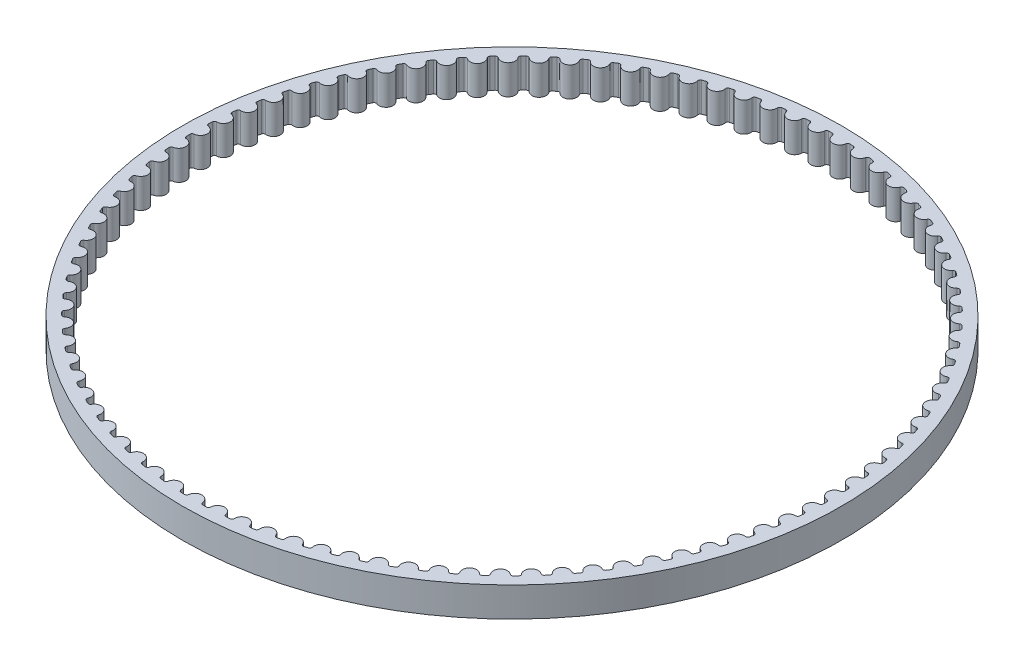
from build123d import *

# Parameters (mm, degrees)
SKETCH1_R           = 44.568299464
BOSS_EXTRUDE1_DEPTH = 4


with BuildPart() as part:
    # Sketch1 → Boss-Extrude1 (new body)
    with BuildSketch(Plane(origin=(0, 0, 0), x_dir=(1, 0, 0), z_dir=(0, 1, 0))):
        Circle(SKETCH1_R)
        with BuildLine():
            ThreePointArc((-1.725274037, -43.033729193), (-1.486551409, -43.042636811), (-1.247783047, -43.050220164))
            ThreePointArc((-1.247783047, -43.050220164), (-1.041950756, -42.976123674), (-0.941665266, -42.781701344))
            ThreePointArc((-0.941665266, -42.781701344), (0, -41.931243432), (0.941665266, -42.781701344))
            ThreePointArc((0.941665266, -42.781701344), (1.041950756, -42.976123674), (1.247783047, -43.050220164))
            ThreePointArc((1.247783047, -43.050220164), (1.486551409, -43.042636811), (1.725274037, -43.033729193))
            ThreePointArc((1.725274037, -43.033729193), (1.925503883, -42.945608649), (2.012137001, -42.744730764))
            ThreePointArc((2.012137001, -42.744730764), (2.892884471, -41.831332697), (3.89098007, -42.614797635))
            ThreePointArc((3.89098007, -42.614797635), (4.004440026, -42.801837898), (4.214893875, -42.861557232))
            ThreePointArc((4.214893875, -42.861557232), (4.452570134, -42.837519045), (4.690109403, -42.812162904))
            ThreePointArc((4.690109403, -42.812162904), (4.883782619, -42.710438241), (4.956350519, -42.504062075))
            ThreePointArc((4.956350519, -42.504062075), (5.771983029, -41.532076611), (6.821752581, -42.244815008))
            ThreePointArc((6.821752581, -42.244815008), (6.947846315, -42.423581874), (7.161918815, -42.46863946))
            ThreePointArc((7.161918815, -42.46863946), (7.397370334, -42.428260993), (7.632594263, -42.386577162))
            ThreePointArc((7.632594263, -42.386577162), (7.818787908, -42.271733145), (7.87694477, -42.060842175))
            ThreePointArc((7.87694477, -42.060842175), (8.62357546, -41.034901267), (9.720016335, -41.6735166))
            ThreePointArc((9.720016335, -41.6735166), (9.858142952, -41.843158162), (10.074813951, -41.873339282))
            ThreePointArc((10.074813951, -41.873339282), (10.306918696, -41.816812955), (10.538706335, -41.759000078))
            ThreePointArc((10.538706335, -41.759000078), (10.716533111, -41.63158399), (10.760001792, -41.417183207))
            ThreePointArc((10.760001792, -41.417183207), (11.434072627, -40.342175932), (12.571959784, -40.903624907))
            ThreePointArc((12.571959784, -40.903624907), (12.721461049, -41.063332746), (12.93969801, -41.078493572))
            ThreePointArc((12.93969801, -41.078493572), (13.167349896, -41.00608876), (13.394596672, -40.932422341))
            ThreePointArc((13.394596672, -40.932422341), (13.563209153, -40.793041378), (13.591782505, -40.5761525))
            ThreePointArc((13.591782505, -40.5761525), (14.190081231, -39.457201756), (15.36399212, -39.938808814))
            ThreePointArc((15.36399212, -39.938808814), (15.52415559, -40.087821849), (15.742918515, -40.087890134))
            ThreePointArc((15.742918515, -40.087890134), (15.965032678, -39.999951879), (16.186655656, -39.910782972))
            ThreePointArc((16.186655656, -39.910782972), (16.345250327, -39.760101347), (16.358792185, -39.541757948))
            ThreePointArc((16.358792185, -39.541757948), (16.878467636, -38.384196045), (18.082808037, -38.783666109))
            ThreePointArc((18.082808037, -38.783666109), (18.252870461, -38.921274226), (18.471116844, -38.906249643))
            ThreePointArc((18.471116844, -38.906249643), (18.686634809, -38.803197011), (18.901577855, -38.698950546))
            ThreePointArc((18.901577855, -38.698950546), (19.04939894, -38.537686327), (19.04784477, -38.318928912))
            ThreePointArc((19.04784477, -38.318928912), (19.486420455, -37.12827216), (20.715451138, -37.443701573))
            ThreePointArc((20.715451138, -37.443701573), (20.894602091, -37.569249006), (21.111291889, -37.539203155))
            ThreePointArc((21.111291889, -37.539203155), (21.319186615, -37.421527238), (21.526425427, -37.302699997))
            ThreePointArc((21.526425427, -37.302699997), (21.662768492, -37.131621681), (21.646125701, -36.91349273))
            ThreePointArc((21.646125701, -36.91349273), (22.001511608, -35.69541515), (23.249375681, -35.925300748))
            ThreePointArc((23.249375681, -35.925300748), (23.436761427, -36.038189205), (23.650862015, -35.993265268))
            ThreePointArc((23.650862015, -35.993265268), (23.850142788, -35.861526846), (24.048689779, -35.728685095))
            ThreePointArc((24.048689779, -35.728685095), (24.172905087, -35.548607948), (24.141252985, -35.332146944))
            ThreePointArc((24.141252985, -35.332146944), (24.411755538, -34.092453231), (25.672506361, -34.235699504))
            ThreePointArc((25.672506361, -34.235699504), (25.867233922, -34.335391022), (26.077725013, -34.275803082))
            ThreePointArc((26.077725013, -34.275803082), (26.267442169, -34.130629948), (26.456351172, -33.984406739))
            ThreePointArc((26.456351172, -33.984406739), (26.567846781, -33.79618891), (26.521336205, -33.582427388))
            ThreePointArc((26.521336205, -33.582427388), (26.705666336, -32.327025247), (27.973295858, -32.38294956))
            ThreePointArc((27.973295858, -32.38294956), (28.174437268, -32.468969063), (28.380315775, -32.395001084))
            ThreePointArc((28.380315775, -32.395001084), (28.559565227, -32.237085054), (28.737936004, -32.078177207))
            ThreePointArc((28.737936004, -32.078177207), (28.836180586, -31.882715641), (28.77503318, -31.672672273))
            ThreePointArc((28.77503318, -31.672672273), (28.872312472, -30.407544266), (30.14077986, -30.375880116))
            ThreePointArc((30.14077986, -30.375880116), (30.347376589, -30.447817681), (30.547661408, -30.359822154))
            ThreePointArc((30.547661408, -30.359822154), (30.71558895, -30.18991577), (30.882571484, -30.019080553))
            ThreePointArc((30.882571484, -30.019080553), (30.967096858, -29.817306712), (30.891604018, -29.61198245))
            ThreePointArc((30.891604018, -29.61198245), (30.90136889, -28.343157489), (32.164629321, -28.224055769))
            ThreePointArc((32.164629321, -28.224055769), (32.375696841, -28.281568582), (32.569433524, -28.179964845))
            ThreePointArc((32.569433524, -28.179964845), (32.725238903, -27.998877789), (32.880037447, -27.816929309))
            ThreePointArc((32.880037447, -27.816929309), (32.950440812, -27.609804738), (32.860962294, -27.410178045))
            ThreePointArc((32.860962294, -27.410178045), (32.783166214, -26.143702659), (34.035199675, -25.937730943))
            ThreePointArc((34.035199675, -25.937730943), (34.249732153, -25.98054493), (34.435997456, -25.865817171))
            ThreePointArc((34.435997456, -25.865817171), (34.578938191, -25.674412404), (34.720815058, -25.48221773))
            ThreePointArc((34.720815058, -25.48221773), (34.77676091, -25.270729472), (34.673723121, -25.07775166))
            ThreePointArc((34.673723121, -25.07775166), (34.508736821, -23.81966118), (35.743576803, -23.527801018))
            ThreePointArc((35.743576803, -23.527801018), (35.960551895, -23.555712149), (36.138458179, -23.428407099))
            ThreePointArc((36.138458179, -23.428407099), (36.267853091, -23.227596753), (36.396132173, -23.026071778))
            ThreePointArc((36.396132173, -23.026071778), (36.437353904, -22.811227671), (36.321247866, -22.625818368))
            ThreePointArc((36.321247866, -22.625818368), (36.069857582, -21.382108169), (37.28161951, -21.005750406))
            ThreePointArc((37.28161951, -21.005750406), (37.50000323, -21.018625672), (37.668702691, -20.879349998))
            ThreePointArc((37.668702691, -20.879349998), (37.783935154, -20.670091025), (37.898005144, -20.460196109))
            ThreePointArc((37.898005144, -20.460196109), (37.924306314, -20.243019982), (37.795685325, -20.066062747))
            ThreePointArc((37.795685325, -20.066062747), (37.459089046, -18.842659674), (38.641998322, -18.383597827))
            ThreePointArc((38.641998322, -18.383597827), (38.860749972, -18.381375873), (39.01943868, -18.230793285))
            ThreePointArc((39.01943868, -18.230793285), (39.11995956, -18.0140829), (39.219276862, -17.796818287))
            ThreePointArc((39.219276862, -17.796818287), (39.230532134, -17.578345084), (39.090009132, -17.410683199))
            ThreePointArc((39.090009132, -17.410683199), (38.669810891, -16.213417325), (39.818230414, -15.673839033))
            ThreePointArc((39.818230414, -15.673839033), (40.036307544, -15.656530446), (40.184229275, -15.49535854))
            ThreePointArc((40.184229275, -15.49535854), (40.269559544, -15.272229467), (40.353650865, -15.048630522))
            ThreePointArc((40.353650865, -15.048630522), (40.349806602, -14.829901367), (40.198051243, -14.672333817))
            ThreePointArc((40.198051243, -14.672333817), (39.696253478, -13.506910659), (40.804710506, -12.889387258))
            ThreePointArc((40.804710506, -12.889387258), (41.021073878, -12.857074522), (41.157523718, -12.686081356))
            ThreePointArc((41.157523718, -12.686081356), (41.227256737, -12.457596905), (41.295721345, -12.228729179))
            ThreePointArc((41.295721345, -12.228729179), (41.276795867, -12.010786416), (41.114531334, -11.864064083))
            ThreePointArc((41.114531334, -11.864064083), (40.533525339, -10.736037413), (41.59673757, -10.043511683))
            ThreePointArc((41.59673757, -10.043511683), (41.810356114, -9.996348783), (41.934683817, -9.816349216))
            ThreePointArc((41.934683817, -9.816349216), (41.988487278, -9.583598221), (42.040998906, -9.350552373))
            ThreePointArc((42.040998906, -9.350552373), (42.007082402, -9.134434598), (41.83508196, -8.999256681))
            ThreePointArc((41.83508196, -8.999256681), (41.177636493, -7.91400206), (42.190537236, -7.149774202))
            ThreePointArc((42.190537236, -7.149774202), (42.400392963, -7.08798589), (42.51200605, -6.899837702))
            ThreePointArc((42.51200605, -6.899837702), (42.549623555, -6.663929327), (42.585931963, -6.427815926))
            ThreePointArc((42.585931963, -6.427815926), (42.53718606, -6.21455304), (42.356269368, -6.091563722))
            ThreePointArc((42.356269368, -6.091563722), (41.625517457, -5.054252882), (42.583279778, -4.22196479))
            ThreePointArc((42.583279778, -4.22196479), (42.78837263, -4.145845516), (42.886739215, -3.95044532))
            ThreePointArc((42.886739215, -3.95044532), (42.907991499, -3.712503775), (42.92792366, -3.47444801))
            ThreePointArc((42.92792366, -3.47444801), (42.864580655, -3.265056306), (42.675609864, -3.154841688))
            ThreePointArc((42.675609864, -3.154841688), (41.875033874, -2.170417888), (42.773093601, -1.274035793))
            ThreePointArc((42.773093601, -1.274035793), (42.972446216, -1.1839483), (43.057097537, -0.982227266))
            ThreePointArc((43.057097537, -0.982227266), (43.061883323, -0.743386451), (43.065344252, -0.504522766))
            ThreePointArc((43.065344252, -0.504522766), (42.987706002, -0.300000092), (42.791581645, -0.203085396))
            ThreePointArc((42.791581645, -0.203085396), (41.924996685, 0.723760136), (42.759074153, 1.679964565))
            ThreePointArc((42.759074153, 1.679964565), (42.951736527, 1.783590969), (43.022269181, 1.990671548))
            ThreePointArc((43.022269181, 1.990671548), (43.010565663, 2.229273447), (42.997538866, 2.467806759))
            ThreePointArc((42.997538866, 2.467806759), (42.905975354, 2.666485759), (42.703632052, 2.749638689))
            ThreePointArc((42.703632052, 2.749638689), (41.775167794, 3.614489113), (42.541288245, 4.625959126))
            ThreePointArc((42.541288245, 4.625959126), (42.726342252, 4.742630614), (42.782420121, 4.954083906))
            ThreePointArc((42.782420121, 4.954083906), (42.75428307, 5.191309842), (42.724830627, 5.42837606))
            ThreePointArc((42.724830627, 5.42837606), (42.619778194, 5.620264591), (42.412180205, 5.689259495))
            ThreePointArc((42.412180205, 5.689259495), (41.426261204, 6.487993403), (42.120773725, 7.549908886))
            ThreePointArc((42.120773725, 7.549908886), (42.2973375, 7.679069465), (42.338693345, 7.893887797))
            ThreePointArc((42.338693345, 7.893887797), (42.294256849, 8.128607281), (42.248519113, 8.363076677))
            ThreePointArc((42.248519113, 8.363076677), (42.130478382, 8.547260302), (41.918615006, 8.601768387))
            ThreePointArc((41.918615006, 8.601768387), (40.879939614, 9.33057945), (41.499534537, 10.437879891))
            ThreePointArc((41.499534537, 10.437879891), (41.666766671, 10.578914053), (41.693203415, 10.796073719))
            ThreePointArc((41.693203415, 10.796073719), (41.632679233, 11.027168205), (41.570874165, 11.257923426))
            ThreePointArc((41.570874165, 11.257923426), (41.440407655, 11.433524426), (41.225288516, 11.473285937))
            ThreePointArc((41.225288516, 11.473285937), (40.138806496, 12.128701037), (40.680531167, 13.276109646))
            ThreePointArc((40.680531167, 13.276109646), (40.837634725, 13.428345298), (40.849026383, 13.646811432))
            ThreePointArc((40.849026383, 13.646811432), (40.772702941, 13.873179651), (40.695125071, 14.099121043))
            ThreePointArc((40.695125071, 14.099121043), (40.552854513, 14.2653026), (40.335504752, 14.290128054))
            ThreePointArc((40.335504752, 14.290128054), (39.206393685, 14.869023841), (39.667666541, 16.051072692))
            ThreePointArc((39.667666541, 16.051072692), (39.813892852, 16.213784362), (39.810185139, 16.432515874))
            ThreePointArc((39.810185139, 16.432515874), (39.718426152, 16.653079078), (39.625445174, 16.873129927))
            ThreePointArc((39.625445174, 16.873129927), (39.472048551, 17.02910011), (39.253503939, 17.038871203))
            ThreePointArc((39.253503939, 17.038871203), (38.087144554, 17.538488974), (38.465767419, 18.749545067))
            ThreePointArc((38.465767419, 18.749545067), (38.600419649, 18.92195736), (38.581630232, 19.139911895))
            ThreePointArc((38.581630232, 19.139911895), (38.474872974, 19.353618999), (38.366931984, 19.566730663))
            ThreePointArc((38.366931984, 19.566730663), (38.203140303, 19.711746203), (37.984442305, 19.706416371))
            ThreePointArc((37.984442305, 19.706416371), (36.786392834, 20.12437522), (37.080561399, 21.358667321))
            ThreePointArc((37.080561399, 21.358667321), (37.202997867, 21.539958614), (37.169216288, 21.75609752))
            ThreePointArc((37.169216288, 21.75609752), (37.047969505, 21.961930112), (36.925582892, 22.167087016))
            ThreePointArc((36.925582892, 22.167087016), (36.752176694, 22.300456849), (36.534367504, 22.280051491))
            ThreePointArc((36.534367504, 22.280051491), (35.3103372, 22.614359654), (35.518649617, 23.866005799))
            ThreePointArc((35.518649617, 23.866005799), (35.628286858, 24.055312156), (35.579674101, 24.268605432))
            ThreePointArc((35.579674101, 24.268605432), (35.44451559, 24.465582627), (35.308266582, 24.661807106))
            ThreePointArc((35.308266582, 24.661807106), (35.126072226, 24.782895662), (34.910189805, 24.747512019))
            ThreePointArc((34.910189805, 24.747512019), (33.666011729, 24.996576366), (33.787475294, 26.25961189))
            ThreePointArc((33.787475294, 26.25961189), (33.883790838, 26.456031181), (33.820578564, 26.665462387))
            ThreePointArc((33.820578564, 26.665462387), (33.672152417, 26.852645499), (33.522690302, 27.039002453))
            ThreePointArc((33.522690302, 27.039002453), (33.332576027, 27.147232691), (33.119649154, 27.097039383))
            ThreePointArc((33.119649154, 27.097039383), (31.861252381, 27.259673008), (31.895288265, 28.528078973))
            ThreePointArc((31.895288265, 28.528078973), (31.977823123, 28.730675169), (31.900312568, 28.935246271))
            ThreePointArc((31.900312568, 28.935246271), (31.739326104, 29.111743287), (31.577363136, 29.287344641))
            ThreePointArc((31.577363136, 29.287344641), (31.380234924, 29.382200794), (31.171278291, 29.317437014))
            ThreePointArc((31.171278291, 29.317437014), (29.904659655, 29.392864894), (29.851105662, 30.660596767))
            ThreePointArc((29.851105662, 30.660596767), (29.919466519, 30.868404407), (29.828027056, 31.067140529))
            ThreePointArc((29.828027056, 31.067140529), (29.655247447, 31.23211036), (29.481555455, 31.396119293))
            ThreePointArc((29.481555455, 31.396119293), (29.278352711, 31.477149329), (29.074362092, 31.398123707))
            ThreePointArc((29.074362092, 31.398123707), (27.805557608, 31.385986393), (27.664668947, 32.647002856))
            ThreePointArc((27.664668947, 32.647002856), (27.718530031, 32.85903164), (27.613597411, 33.050985715))
            ThreePointArc((27.613597411, 33.050985715), (27.429848032, 33.203642205), (27.245254736, 33.35527714))
            ThreePointArc((27.245254736, 33.35527714), (27.036945815, 33.422094914), (26.838893318, 33.329184041))
            ThreePointArc((26.838893318, 33.329184041), (25.573949416, 33.229539374), (25.346397485, 34.477831108))
            ThreePointArc((25.346397485, 34.477831108), (25.385502125, 34.693070623), (25.2675764, 34.877327902))
            ThreePointArc((25.2675764, 34.877327902), (25.073732899, 35.016943573), (24.879117971, 35.155481901))
            ThreePointArc((24.879117971, 35.155481901), (24.666695558, 35.207768995), (24.475524994, 35.101415636))
            ThreePointArc((24.475524994, 35.101415636), (23.220469709, 34.914738467), (22.907338897, 36.144356794))
            ThreePointArc((22.907338897, 36.144356794), (22.931500741, 36.361781325), (22.80114388, 36.537463739))
            ThreePointArc((22.80114388, 36.537463739), (22.598130011, 36.663373259), (22.394420879, 36.788154781))
            ThreePointArc((22.394420879, 36.788154781), (22.178897265, 36.825662024), (21.995519648, 36.706373))
            ThreePointArc((21.995519648, 36.706373), (20.756333889, 36.433552932), (20.359116407, 37.638638159))
            ThreePointArc((20.359116407, 37.638638159), (20.368220313, 37.857211581), (20.226053526, 38.023481922))
            ThreePointArc((20.226053526, 38.023481922), (20.014836741, 38.135085275), (19.803004174, 38.245515351))
            ThreePointArc((19.803004174, 38.245515351), (19.585406426, 38.268064003), (19.410695634, 38.13640778))
            ThreePointArc((19.410695634, 38.13640778), (18.193284686, 37.778744925), (17.713873456, 38.953554274))
            ThreePointArc((17.713873456, 38.953554274), (17.707876039, 39.172234983), (17.554576816, 39.328300898))
            ThreePointArc((17.554576816, 39.328300898), (17.336163661, 39.425066243), (17.117217135, 39.520618622))
            ThreePointArc((17.117217135, 39.520618622), (16.898582205, 39.52810123), (16.733370815, 39.384705211))
            ThreePointArc((16.733370815, 39.384705211), (15.543536196, 38.943903994), (14.984215831, 40.082838963))
            ThreePointArc((14.984215831, 40.082838963), (14.963145672, 40.300584847), (14.799444553, 40.44570261))
            ThreePointArc((14.799444553, 40.44570261), (14.574875865, 40.527168816), (14.349858761, 40.607388149))
            ThreePointArc((14.349858761, 40.607388149), (14.131228546, 40.599769053), (13.976303865, 40.445316585))
            ThreePointArc((13.976303865, 40.445316585), (12.819715678, 39.923477625), (12.183151594, 41.02111067))
            ThreePointArc((12.183151594, 41.02111067), (12.147109102, 41.236884071), (11.973786197, 41.370362131))
            ThreePointArc((11.973786197, 41.370362131), (11.744132148, 41.436140974), (11.514116775, 41.500644978))
            ThreePointArc((11.514116775, 41.500644978), (11.296533146, 41.477960488), (11.152633461, 41.313187607))
            ThreePointArc((11.152633461, 41.313187607), (10.034803376, 40.712797705), (9.324029092, 41.763898104))
            ThreePointArc((9.324029092, 41.763898104), (9.273186025, 41.976670763), (9.091067297, 42.097873036))
            ThreePointArc((9.091067297, 42.097873036), (8.857422294, 42.14765105), (8.62350478, 42.196132335))
            ThreePointArc((8.62350478, 42.196132335), (8.408004622, 42.158490553), (8.275815681, 41.984182476))
            ThreePointArc((8.275815681, 41.984182476), (7.202070667, 41.308102763), (6.420473344, 42.307661545))
            ThreePointArc((6.420473344, 42.307661545), (6.355071993, 42.516419503), (6.165025322, 42.624768404))
            ThreePointArc((6.165025322, 42.624768404), (5.928502789, 42.658308375), (5.691797857, 42.690535905))
            ThreePointArc((5.691797857, 42.690535905), (5.479408127, 42.63811621), (5.35955987, 42.455103596))
            ThreePointArc((5.35955987, 42.455103596), (4.335016811, 41.706555899), (3.486321118, 42.649809712))
            ThreePointArc((3.486321118, 42.649809712), (3.40667315, 42.853558142), (3.209604193, 42.94853734))
            ThreePointArc((3.209604193, 42.94853734), (2.971331268, 42.965679434), (2.732966925, 42.981499631))
            ThreePointArc((2.732966925, 42.981499631), (2.524699757, 42.914551827), (2.417763315, 42.723706814))
            ThreePointArc((2.417763315, 42.723706814), (1.447304625, 41.906258304), (0.535554983, 42.788712112))
            ThreePointArc((0.535554983, 42.788712112), (0.442039957, 42.986480061), (0.238887839, 43.067636937))
            ThreePointArc((0.238887839, 43.067636937), (0, 43.068299464), (-0.238887839, 43.067636937))
            ThreePointArc((-0.238887839, 43.067636937), (-0.442039957, 42.986480061), (-0.535554983, 42.788712112))
            ThreePointArc((-0.535554983, 42.788712112), (-1.447304625, 41.906258304), (-2.417763315, 42.723706814))
            ThreePointArc((-2.417763315, 42.723706814), (-2.524699757, 42.914551827), (-2.732966925, 42.981499631))
            ThreePointArc((-2.732966925, 42.981499631), (-2.971331268, 42.965679434), (-3.209604193, 42.94853734))
            ThreePointArc((-3.209604193, 42.94853734), (-3.40667315, 42.853558142), (-3.486321118, 42.649809712))
            ThreePointArc((-3.486321118, 42.649809712), (-4.335016811, 41.706555899), (-5.35955987, 42.455103596))
            ThreePointArc((-5.35955987, 42.455103596), (-5.479408127, 42.63811621), (-5.691797857, 42.690535905))
            ThreePointArc((-5.691797857, 42.690535905), (-5.928502789, 42.658308375), (-6.165025322, 42.624768404))
            ThreePointArc((-6.165025322, 42.624768404), (-6.355071993, 42.516419503), (-6.420473344, 42.307661545))
            ThreePointArc((-6.420473344, 42.307661545), (-7.202070667, 41.308102763), (-8.275815681, 41.984182476))
            ThreePointArc((-8.275815681, 41.984182476), (-8.408004622, 42.158490553), (-8.62350478, 42.196132335))
            ThreePointArc((-8.62350478, 42.196132335), (-8.857422294, 42.14765105), (-9.091067297, 42.097873036))
            ThreePointArc((-9.091067297, 42.097873036), (-9.273186025, 41.976670763), (-9.324029092, 41.763898104))
            ThreePointArc((-9.324029092, 41.763898104), (-10.034803376, 40.712797705), (-11.152633461, 41.313187607))
            ThreePointArc((-11.152633461, 41.313187607), (-11.296533146, 41.477960488), (-11.514116775, 41.500644978))
            ThreePointArc((-11.514116775, 41.500644978), (-11.744132148, 41.436140974), (-11.973786197, 41.370362131))
            ThreePointArc((-11.973786197, 41.370362131), (-12.147109102, 41.236884071), (-12.183151594, 41.02111067))
            ThreePointArc((-12.183151594, 41.02111067), (-12.819715678, 39.923477625), (-13.976303865, 40.445316585))
            ThreePointArc((-13.976303865, 40.445316585), (-14.131228546, 40.599769053), (-14.349858761, 40.607388149))
            ThreePointArc((-14.349858761, 40.607388149), (-14.574875865, 40.527168816), (-14.799444553, 40.44570261))
            ThreePointArc((-14.799444553, 40.44570261), (-14.963145672, 40.300584847), (-14.984215831, 40.082838963))
            ThreePointArc((-14.984215831, 40.082838963), (-15.543536196, 38.943903994), (-16.733370815, 39.384705211))
            ThreePointArc((-16.733370815, 39.384705211), (-16.898582205, 39.52810123), (-17.117217135, 39.520618622))
            ThreePointArc((-17.117217135, 39.520618622), (-17.336163661, 39.425066243), (-17.554576816, 39.328300898))
            ThreePointArc((-17.554576816, 39.328300898), (-17.707876039, 39.172234983), (-17.713873456, 38.953554274))
            ThreePointArc((-17.713873456, 38.953554274), (-18.193284686, 37.778744925), (-19.410695634, 38.13640778))
            ThreePointArc((-19.410695634, 38.13640778), (-19.585406426, 38.268064003), (-19.803004174, 38.245515351))
            ThreePointArc((-19.803004174, 38.245515351), (-20.014836741, 38.135085275), (-20.226053526, 38.023481922))
            ThreePointArc((-20.226053526, 38.023481922), (-20.368220313, 37.857211581), (-20.359116407, 37.638638159))
            ThreePointArc((-20.359116407, 37.638638159), (-20.756333889, 36.433552932), (-21.995519648, 36.706373))
            ThreePointArc((-21.995519648, 36.706373), (-22.178897265, 36.825662024), (-22.394420879, 36.788154781))
            ThreePointArc((-22.394420879, 36.788154781), (-22.598130011, 36.663373259), (-22.80114388, 36.537463739))
            ThreePointArc((-22.80114388, 36.537463739), (-22.931500741, 36.361781325), (-22.907338897, 36.144356794))
            ThreePointArc((-22.907338897, 36.144356794), (-23.220469709, 34.914738467), (-24.475524994, 35.101415636))
            ThreePointArc((-24.475524994, 35.101415636), (-24.666695558, 35.207768995), (-24.879117971, 35.155481901))
            ThreePointArc((-24.879117971, 35.155481901), (-25.073732899, 35.016943573), (-25.2675764, 34.877327902))
            ThreePointArc((-25.2675764, 34.877327902), (-25.385502125, 34.693070623), (-25.346397485, 34.477831108))
            ThreePointArc((-25.346397485, 34.477831108), (-25.573949416, 33.229539374), (-26.838893318, 33.329184041))
            ThreePointArc((-26.838893318, 33.329184041), (-27.036945815, 33.422094914), (-27.245254736, 33.35527714))
            ThreePointArc((-27.245254736, 33.35527714), (-27.429848032, 33.203642205), (-27.613597411, 33.050985715))
            ThreePointArc((-27.613597411, 33.050985715), (-27.718530031, 32.85903164), (-27.664668947, 32.647002856))
            ThreePointArc((-27.664668947, 32.647002856), (-27.805557608, 31.385986393), (-29.074362092, 31.398123707))
            ThreePointArc((-29.074362092, 31.398123707), (-29.278352711, 31.477149329), (-29.481555455, 31.396119293))
            ThreePointArc((-29.481555455, 31.396119293), (-29.655247447, 31.23211036), (-29.828027056, 31.067140529))
            ThreePointArc((-29.828027056, 31.067140529), (-29.919466519, 30.868404407), (-29.851105662, 30.660596767))
            ThreePointArc((-29.851105662, 30.660596767), (-29.904659655, 29.392864894), (-31.171278291, 29.317437014))
            ThreePointArc((-31.171278291, 29.317437014), (-31.380234924, 29.382200794), (-31.577363136, 29.287344641))
            ThreePointArc((-31.577363136, 29.287344641), (-31.739326104, 29.111743287), (-31.900312568, 28.935246271))
            ThreePointArc((-31.900312568, 28.935246271), (-31.977823123, 28.730675169), (-31.895288265, 28.528078973))
            ThreePointArc((-31.895288265, 28.528078973), (-31.861252381, 27.259673008), (-33.119649154, 27.097039383))
            ThreePointArc((-33.119649154, 27.097039383), (-33.332576027, 27.147232691), (-33.522690302, 27.039002453))
            ThreePointArc((-33.522690302, 27.039002453), (-33.672152417, 26.852645499), (-33.820578564, 26.665462387))
            ThreePointArc((-33.820578564, 26.665462387), (-33.883790838, 26.456031181), (-33.787475294, 26.25961189))
            ThreePointArc((-33.787475294, 26.25961189), (-33.666011729, 24.996576366), (-34.910189805, 24.747512019))
            ThreePointArc((-34.910189805, 24.747512019), (-35.126072226, 24.782895662), (-35.308266582, 24.661807106))
            ThreePointArc((-35.308266582, 24.661807106), (-35.44451559, 24.465582627), (-35.579674101, 24.268605432))
            ThreePointArc((-35.579674101, 24.268605432), (-35.628286858, 24.055312156), (-35.518649617, 23.866005799))
            ThreePointArc((-35.518649617, 23.866005799), (-35.3103372, 22.614359654), (-36.534367504, 22.280051491))
            ThreePointArc((-36.534367504, 22.280051491), (-36.752176694, 22.300456849), (-36.925582892, 22.167087016))
            ThreePointArc((-36.925582892, 22.167087016), (-37.047969505, 21.961930112), (-37.169216288, 21.75609752))
            ThreePointArc((-37.169216288, 21.75609752), (-37.202997867, 21.539958614), (-37.080561399, 21.358667321))
            ThreePointArc((-37.080561399, 21.358667321), (-36.786392834, 20.12437522), (-37.984442305, 19.706416371))
            ThreePointArc((-37.984442305, 19.706416371), (-38.203140303, 19.711746203), (-38.366931984, 19.566730663))
            ThreePointArc((-38.366931984, 19.566730663), (-38.474872974, 19.353618999), (-38.581630232, 19.139911895))
            ThreePointArc((-38.581630232, 19.139911895), (-38.600419649, 18.92195736), (-38.465767419, 18.749545067))
            ThreePointArc((-38.465767419, 18.749545067), (-38.087144554, 17.538488974), (-39.253503939, 17.038871203))
            ThreePointArc((-39.253503939, 17.038871203), (-39.472048551, 17.02910011), (-39.625445174, 16.873129927))
            ThreePointArc((-39.625445174, 16.873129927), (-39.718426152, 16.653079078), (-39.810185139, 16.432515874))
            ThreePointArc((-39.810185139, 16.432515874), (-39.813892852, 16.213784362), (-39.667666541, 16.051072692))
            ThreePointArc((-39.667666541, 16.051072692), (-39.206393685, 14.869023841), (-40.335504752, 14.290128054))
            ThreePointArc((-40.335504752, 14.290128054), (-40.552854513, 14.2653026), (-40.695125071, 14.099121043))
            ThreePointArc((-40.695125071, 14.099121043), (-40.772702941, 13.873179651), (-40.849026383, 13.646811432))
            ThreePointArc((-40.849026383, 13.646811432), (-40.837634725, 13.428345298), (-40.680531167, 13.276109646))
            ThreePointArc((-40.680531167, 13.276109646), (-40.138806496, 12.128701037), (-41.225288516, 11.473285937))
            ThreePointArc((-41.225288516, 11.473285937), (-41.440407655, 11.433524426), (-41.570874165, 11.257923426))
            ThreePointArc((-41.570874165, 11.257923426), (-41.632679233, 11.027168205), (-41.693203415, 10.796073719))
            ThreePointArc((-41.693203415, 10.796073719), (-41.666766671, 10.578914053), (-41.499534537, 10.437879891))
            ThreePointArc((-41.499534537, 10.437879891), (-40.879939614, 9.33057945), (-41.918615006, 8.601768387))
            ThreePointArc((-41.918615006, 8.601768387), (-42.130478382, 8.547260302), (-42.248519113, 8.363076677))
            ThreePointArc((-42.248519113, 8.363076677), (-42.294256849, 8.128607281), (-42.338693345, 7.893887797))
            ThreePointArc((-42.338693345, 7.893887797), (-42.2973375, 7.679069465), (-42.120773725, 7.549908886))
            ThreePointArc((-42.120773725, 7.549908886), (-41.426261204, 6.487993403), (-42.412180205, 5.689259495))
            ThreePointArc((-42.412180205, 5.689259495), (-42.619778194, 5.620264591), (-42.724830627, 5.42837606))
            ThreePointArc((-42.724830627, 5.42837606), (-42.75428307, 5.191309842), (-42.782420121, 4.954083906))
            ThreePointArc((-42.782420121, 4.954083906), (-42.726342252, 4.742630614), (-42.541288245, 4.625959126))
            ThreePointArc((-42.541288245, 4.625959126), (-41.775167794, 3.614489113), (-42.703632052, 2.749638689))
            ThreePointArc((-42.703632052, 2.749638689), (-42.905975354, 2.666485759), (-42.997538866, 2.467806759))
            ThreePointArc((-42.997538866, 2.467806759), (-43.010565663, 2.229273447), (-43.022269181, 1.990671548))
            ThreePointArc((-43.022269181, 1.990671548), (-42.951736527, 1.783590969), (-42.759074153, 1.679964565))
            ThreePointArc((-42.759074153, 1.679964565), (-41.924996685, 0.723760136), (-42.791581645, -0.203085396))
            ThreePointArc((-42.791581645, -0.203085396), (-42.987706002, -0.300000092), (-43.065344252, -0.504522766))
            ThreePointArc((-43.065344252, -0.504522766), (-43.061883323, -0.743386451), (-43.057097537, -0.982227266))
            ThreePointArc((-43.057097537, -0.982227266), (-42.972446216, -1.1839483), (-42.773093601, -1.274035793))
            ThreePointArc((-42.773093601, -1.274035793), (-41.875033874, -2.170417888), (-42.675609864, -3.154841688))
            ThreePointArc((-42.675609864, -3.154841688), (-42.864580655, -3.265056306), (-42.92792366, -3.47444801))
            ThreePointArc((-42.92792366, -3.47444801), (-42.907991499, -3.712503775), (-42.886739215, -3.95044532))
            ThreePointArc((-42.886739215, -3.95044532), (-42.78837263, -4.145845516), (-42.583279778, -4.22196479))
            ThreePointArc((-42.583279778, -4.22196479), (-41.625517457, -5.054252882), (-42.356269368, -6.091563722))
            ThreePointArc((-42.356269368, -6.091563722), (-42.53718606, -6.21455304), (-42.585931963, -6.427815926))
            ThreePointArc((-42.585931963, -6.427815926), (-42.549623555, -6.663929327), (-42.51200605, -6.899837702))
            ThreePointArc((-42.51200605, -6.899837702), (-42.400392963, -7.08798589), (-42.190537236, -7.149774202))
            ThreePointArc((-42.190537236, -7.149774202), (-41.177636493, -7.91400206), (-41.83508196, -8.999256681))
            ThreePointArc((-41.83508196, -8.999256681), (-42.007082402, -9.134434598), (-42.040998906, -9.350552373))
            ThreePointArc((-42.040998906, -9.350552373), (-41.988487278, -9.583598221), (-41.934683817, -9.816349216))
            ThreePointArc((-41.934683817, -9.816349216), (-41.810356114, -9.996348783), (-41.59673757, -10.043511683))
            ThreePointArc((-41.59673757, -10.043511683), (-40.533525339, -10.736037413), (-41.114531334, -11.864064083))
            ThreePointArc((-41.114531334, -11.864064083), (-41.276795867, -12.010786416), (-41.295721345, -12.228729179))
            ThreePointArc((-41.295721345, -12.228729179), (-41.227256737, -12.457596905), (-41.157523718, -12.686081356))
            ThreePointArc((-41.157523718, -12.686081356), (-41.021073878, -12.857074522), (-40.804710506, -12.889387258))
            ThreePointArc((-40.804710506, -12.889387258), (-39.696253478, -13.506910659), (-40.198051243, -14.672333817))
            ThreePointArc((-40.198051243, -14.672333817), (-40.349806602, -14.829901367), (-40.353650865, -15.048630522))
            ThreePointArc((-40.353650865, -15.048630522), (-40.269559544, -15.272229467), (-40.184229275, -15.49535854))
            ThreePointArc((-40.184229275, -15.49535854), (-40.036307544, -15.656530446), (-39.818230414, -15.673839033))
            ThreePointArc((-39.818230414, -15.673839033), (-38.669810891, -16.213417325), (-39.090009132, -17.410683199))
            ThreePointArc((-39.090009132, -17.410683199), (-39.230532134, -17.578345084), (-39.219276862, -17.796818287))
            ThreePointArc((-39.219276862, -17.796818287), (-39.11995956, -18.0140829), (-39.01943868, -18.230793285))
            ThreePointArc((-39.01943868, -18.230793285), (-38.860749972, -18.381375873), (-38.641998322, -18.383597827))
            ThreePointArc((-38.641998322, -18.383597827), (-37.459089046, -18.842659674), (-37.795685325, -20.066062747))
            ThreePointArc((-37.795685325, -20.066062747), (-37.924306314, -20.243019982), (-37.898005144, -20.460196109))
            ThreePointArc((-37.898005144, -20.460196109), (-37.783935154, -20.670091025), (-37.668702691, -20.879349998))
            ThreePointArc((-37.668702691, -20.879349998), (-37.50000323, -21.018625672), (-37.28161951, -21.005750406))
            ThreePointArc((-37.28161951, -21.005750406), (-36.069857582, -21.382108169), (-36.321247866, -22.625818368))
            ThreePointArc((-36.321247866, -22.625818368), (-36.437353904, -22.811227671), (-36.396132173, -23.026071778))
            ThreePointArc((-36.396132173, -23.026071778), (-36.267853091, -23.227596753), (-36.138458179, -23.428407099))
            ThreePointArc((-36.138458179, -23.428407099), (-35.960551895, -23.555712149), (-35.743576803, -23.527801018))
            ThreePointArc((-35.743576803, -23.527801018), (-34.508736821, -23.81966118), (-34.673723121, -25.07775166))
            ThreePointArc((-34.673723121, -25.07775166), (-34.77676091, -25.270729472), (-34.720815058, -25.48221773))
            ThreePointArc((-34.720815058, -25.48221773), (-34.578938191, -25.674412404), (-34.435997456, -25.865817171))
            ThreePointArc((-34.435997456, -25.865817171), (-34.249732153, -25.98054493), (-34.035199675, -25.937730943))
            ThreePointArc((-34.035199675, -25.937730943), (-32.783166214, -26.143702659), (-32.860962294, -27.410178045))
            ThreePointArc((-32.860962294, -27.410178045), (-32.950440812, -27.609804738), (-32.880037447, -27.816929309))
            ThreePointArc((-32.880037447, -27.816929309), (-32.725238903, -27.998877789), (-32.569433524, -28.179964845))
            ThreePointArc((-32.569433524, -28.179964845), (-32.375696841, -28.281568582), (-32.164629321, -28.224055769))
            ThreePointArc((-32.164629321, -28.224055769), (-30.90136889, -28.343157489), (-30.891604018, -29.61198245))
            ThreePointArc((-30.891604018, -29.61198245), (-30.967096858, -29.817306712), (-30.882571484, -30.019080553))
            ThreePointArc((-30.882571484, -30.019080553), (-30.71558895, -30.18991577), (-30.547661408, -30.359822154))
            ThreePointArc((-30.547661408, -30.359822154), (-30.347376589, -30.447817681), (-30.14077986, -30.375880116))
            ThreePointArc((-30.14077986, -30.375880116), (-28.872312472, -30.407544266), (-28.77503318, -31.672672273))
            ThreePointArc((-28.77503318, -31.672672273), (-28.836180586, -31.882715641), (-28.737936004, -32.078177207))
            ThreePointArc((-28.737936004, -32.078177207), (-28.559565227, -32.237085054), (-28.380315775, -32.395001084))
            ThreePointArc((-28.380315775, -32.395001084), (-28.174437268, -32.468969063), (-27.973295858, -32.38294956))
            ThreePointArc((-27.973295858, -32.38294956), (-26.705666336, -32.327025247), (-26.521336205, -33.582427388))
            ThreePointArc((-26.521336205, -33.582427388), (-26.567846781, -33.79618891), (-26.456351172, -33.984406739))
            ThreePointArc((-26.456351172, -33.984406739), (-26.267442169, -34.130629948), (-26.077725013, -34.275803082))
            ThreePointArc((-26.077725013, -34.275803082), (-25.867233922, -34.335391022), (-25.672506361, -34.235699504))
            ThreePointArc((-25.672506361, -34.235699504), (-24.411755538, -34.092453231), (-24.141252985, -35.332146944))
            ThreePointArc((-24.141252985, -35.332146944), (-24.172905087, -35.548607948), (-24.048689779, -35.728685095))
            ThreePointArc((-24.048689779, -35.728685095), (-23.850142788, -35.861526846), (-23.650862015, -35.993265268))
            ThreePointArc((-23.650862015, -35.993265268), (-23.436761427, -36.038189205), (-23.249375681, -35.925300748))
            ThreePointArc((-23.249375681, -35.925300748), (-22.001511608, -35.69541515), (-21.646125701, -36.91349273))
            ThreePointArc((-21.646125701, -36.91349273), (-21.662768492, -37.131621681), (-21.526425427, -37.302699997))
            ThreePointArc((-21.526425427, -37.302699997), (-21.319186615, -37.421527238), (-21.111291889, -37.539203155))
            ThreePointArc((-21.111291889, -37.539203155), (-20.894602091, -37.569249006), (-20.715451138, -37.443701573))
            ThreePointArc((-20.715451138, -37.443701573), (-19.486420455, -37.12827216), (-19.04784477, -38.318928912))
            ThreePointArc((-19.04784477, -38.318928912), (-19.04939894, -38.537686327), (-18.901577855, -38.698950546))
            ThreePointArc((-18.901577855, -38.698950546), (-18.686634809, -38.803197011), (-18.471116844, -38.906249643))
            ThreePointArc((-18.471116844, -38.906249643), (-18.252870461, -38.921274226), (-18.082808037, -38.783666109))
            ThreePointArc((-18.082808037, -38.783666109), (-16.878467636, -38.384196045), (-16.358792185, -39.541757948))
            ThreePointArc((-16.358792185, -39.541757948), (-16.345250327, -39.760101347), (-16.186655656, -39.910782972))
            ThreePointArc((-16.186655656, -39.910782972), (-15.965032678, -39.999951879), (-15.742918515, -40.087890134))
            ThreePointArc((-15.742918515, -40.087890134), (-15.52415559, -40.087821849), (-15.36399212, -39.938808814))
            ThreePointArc((-15.36399212, -39.938808814), (-14.190081231, -39.457201756), (-13.591782505, -40.5761525))
            ThreePointArc((-13.591782505, -40.5761525), (-13.563209153, -40.793041378), (-13.394596672, -40.932422341))
            ThreePointArc((-13.394596672, -40.932422341), (-13.167349896, -41.00608876), (-12.93969801, -41.078493572))
            ThreePointArc((-12.93969801, -41.078493572), (-12.721461049, -41.063332746), (-12.571959784, -40.903624907))
            ThreePointArc((-12.571959784, -40.903624907), (-11.434072627, -40.342175932), (-10.760001792, -41.417183207))
            ThreePointArc((-10.760001792, -41.417183207), (-10.716533111, -41.63158399), (-10.538706335, -41.759000078))
            ThreePointArc((-10.538706335, -41.759000078), (-10.306918696, -41.816812955), (-10.074813951, -41.873339282))
            ThreePointArc((-10.074813951, -41.873339282), (-9.858142952, -41.843158162), (-9.720016335, -41.6735166))
            ThreePointArc((-9.720016335, -41.6735166), (-8.62357546, -41.034901267), (-7.87694477, -42.060842175))
            ThreePointArc((-7.87694477, -42.060842175), (-7.818787908, -42.271733145), (-7.632594263, -42.386577162))
            ThreePointArc((-7.632594263, -42.386577162), (-7.397370334, -42.428260993), (-7.161918815, -42.46863946))
            ThreePointArc((-7.161918815, -42.46863946), (-6.947846315, -42.423581874), (-6.821752581, -42.244815008))
            ThreePointArc((-6.821752581, -42.244815008), (-5.771983029, -41.532076611), (-4.956350519, -42.504062075))
            ThreePointArc((-4.956350519, -42.504062075), (-4.883782619, -42.710438241), (-4.690109403, -42.812162904))
            ThreePointArc((-4.690109403, -42.812162904), (-4.452570134, -42.837519045), (-4.214893875, -42.861557232))
            ThreePointArc((-4.214893875, -42.861557232), (-4.004440026, -42.801837898), (-3.89098007, -42.614797635))
            ThreePointArc((-3.89098007, -42.614797635), (-2.892884471, -41.831332697), (-2.012137001, -42.744730764))
            ThreePointArc((-2.012137001, -42.744730764), (-1.925503883, -42.945608649), (-1.725274037, -43.033729193))
        make_face(mode=Mode.SUBTRACT)
    extrude(amount=BOSS_EXTRUDE1_DEPTH)


solid = part.part
